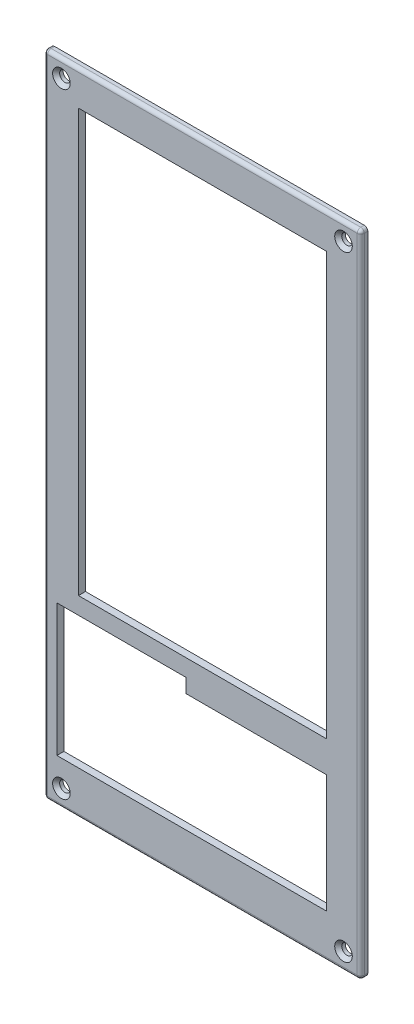
from build123d import *

# Parameters (mm, degrees)
IZIM1_R                              = 1.5
N_PANEL_DEPTH                        = 2
VIDA_DELIKLERI_45DERECE_PAH_1MM_SIZE = 1
IZIM2_W                              = 70.48450085
IZIM2_H                              = 120
EKRAN_VE_KONTROLC_DELIKLERI_DEPTH    = 2
FILLET1_R                            = 1


with BuildPart() as part:
    # Çizim1 → Ön Panel (new body)
    with BuildSketch(Plane(origin=(0, 0, 0), x_dir=(0, 1, 0), z_dir=(0, 0, 1))):
        with BuildLine():
            Line((-1, 0), (-183.6, 0))
            ThreePointArc((-183.6, 0), (-184.307106781, -0.292893219), (-184.6, -1))
            Line((-184.6, -1), (-184.6, -89))
            ThreePointArc((-184.6, -89), (-184.307106781, -89.707106781), (-183.6, -90))
            Line((-183.6, -90), (-1, -90))
            ThreePointArc((-1, -90), (-0.292893219, -89.707106781), (0, -89))
            Line((0, -89), (0, -1))
            ThreePointArc((0, -1), (-0.292893219, -0.292893219), (-1, 0))
        make_face()
        with Locations((-179.693599404, -4.906400596)):
            Circle(IZIM1_R, mode=Mode.SUBTRACT)
        with Locations((-4.906400596, -4.906400596)):
            Circle(IZIM1_R, mode=Mode.SUBTRACT)
        with Locations((-179.693599404, -85.093599404)):
            Circle(IZIM1_R, mode=Mode.SUBTRACT)
        with Locations((-4.906400596, -85.093599404)):
            Circle(IZIM1_R, mode=Mode.SUBTRACT)
    extrude(amount=N_PANEL_DEPTH)

    # Vida Delikleri 45derece Pah 1mm
    vida_delikleri_45derece_pah_1mm_edges = [part.edges().sort_by_distance(p)[0] for p in [
        (85.093599404, -6.406400596, 2),
        (4.906400596, -6.406400596, 2),
        (4.906400596, -181.193599404, 2),
        (85.093599404, -181.193599404, 2),
    ]]
    chamfer(vida_delikleri_45derece_pah_1mm_edges, length=VIDA_DELIKLERI_45DERECE_PAH_1MM_SIZE)

    # Çizim2 → Ekran ve Kontrolcü delikleri (cut)
    with BuildSketch(Plane.XY.offset(2)):
        with Locations((45, -69.798366298)):
            Rectangle(IZIM2_W, IZIM2_H)
        Polygon((40.317046277, -138.653704662), (40.317046277, -134.653704662), (3.616207615, -134.653704662), (3.616207615, -172.224363873), (80.242250425, -172.224363873), (80.242250425, -138.653704662), align=None)
    extrude(amount=-EKRAN_VE_KONTROLC_DELIKLERI_DEPTH, mode=Mode.SUBTRACT)

    # Fillet1
    fillet1_edges = [part.edges().sort_by_distance(p)[0] for p in [
        (0, -92.3, 2),
        (45, -184.6, 2),
        (90, -92.3, 2),
        (45, 0, 2),
    ]]
    fillet(fillet1_edges, radius=FILLET1_R)


solid = part.part
